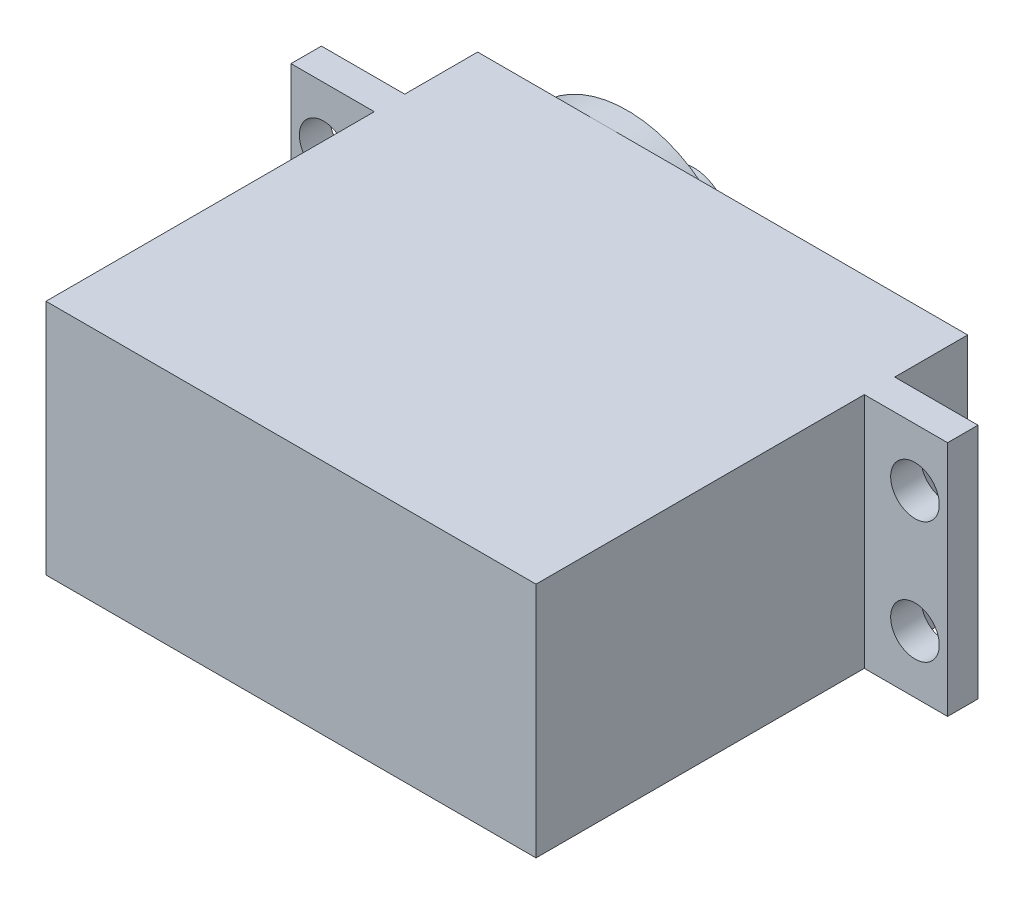
from build123d import *

# Parameters (mm, degrees)
SKETCH_1_W          = 40.3
SKETCH_1_H          = 19.5
EXTRUDE_1_DEPTH     = 27
SKETCH_2_W          = 6.85
SKETCH_2_H          = 19.5
SKETCH_2_R          = 2
SKETCH_2_W_2        = 20.15
EXTRUDE_2_DEPTH     = 2.5
SKETCH_3_W          = 40.3
SKETCH_3_H          = 19.5
EXTRUDE_3_DEPTH     = 6
EXTRUDE_4_DEPTH     = 2
SKETCH_5_R          = 6
EXTRUDE_5_DEPTH     = 1
SKETCH_6_R          = 2.9
EXTRUDE_6_DEPTH     = 4.5
SKETCH_7_R          = 1.5
CUT_EXTRUDE_1_DEPTH = 4.5


with BuildPart() as part:
    # 草图1 → 凸台-拉伸1 (new body)
    with BuildSketch(Plane.XY):
        Rectangle(SKETCH_1_W, SKETCH_1_H)
    extrude(amount=EXTRUDE_1_DEPTH)

    # 草图2 → 凸台-拉伸2 (add)
    with BuildSketch(Plane(origin=(0, 0, 0), x_dir=(-1, 0, 0), z_dir=(0, 0, -1))):
        with Locations((23.575, 0)):
            Rectangle(SKETCH_2_W, SKETCH_2_H)
        with Locations((24.315, -5)):
            Circle(SKETCH_2_R, mode=Mode.SUBTRACT)
        with Locations((24.315, 5)):
            Circle(SKETCH_2_R, mode=Mode.SUBTRACT)
        with Locations((10.075, 0)):
            Rectangle(SKETCH_2_W_2, SKETCH_2_H)
        with Locations((-23.575, 0)):
            Rectangle(SKETCH_2_W, SKETCH_2_H)
        with Locations((-24.315, -5)):
            Circle(SKETCH_2_R, mode=Mode.SUBTRACT)
        with Locations((-24.315, 5)):
            Circle(SKETCH_2_R, mode=Mode.SUBTRACT)
        with Locations((-10.075, 0)):
            Rectangle(SKETCH_2_W_2, SKETCH_2_H)
    extrude(amount=EXTRUDE_2_DEPTH)

    # 草图3 → 凸台-拉伸3 (add)
    with BuildSketch(Plane(origin=(0, 0, -2.5), x_dir=(-1, 0, 0), z_dir=(0, 0, -1))):
        Rectangle(SKETCH_3_W, SKETCH_3_H)
    extrude(amount=EXTRUDE_3_DEPTH)

    # 草图4 → 凸台-拉伸4 (add)
    with BuildSketch(Plane(origin=(0, 0, -8.5), x_dir=(-1, 0, 0), z_dir=(0, 0, -1))):
        with BuildLine():
            Line((3.774052971, 7.62531099), (-15.211090867, 7.62531099))
            Line((-15.211090867, 7.62531099), (-15.211090867, -7.62531099))
            Line((-15.211090867, -7.62531099), (3.774052971, -7.62531099))
            ThreePointArc((3.774052971, -7.62531099), (19.6, 0), (3.774052971, 7.62531099))
        make_face()
    extrude(amount=EXTRUDE_4_DEPTH)

    # 草图5 → 凸台-拉伸5 (add)
    with BuildSketch(Plane(origin=(0, 0, -10.5), x_dir=(-1, 0, 0), z_dir=(0, 0, -1))):
        with Locations((9.85, 0)):
            Circle(SKETCH_5_R)
    extrude(amount=EXTRUDE_5_DEPTH)

    # 草图6 → 凸台-拉伸6 (add)
    with BuildSketch(Plane(origin=(0, 0, -11.5), x_dir=(-1, 0, 0), z_dir=(0, 0, -1))):
        with Locations((9.85, 0)):
            Circle(SKETCH_6_R)
    extrude(amount=EXTRUDE_6_DEPTH)

    # 草图7 → 切除-拉伸1 (cut)
    with BuildSketch(Plane(origin=(0, 0, -16), x_dir=(-1, 0, 0), z_dir=(0, 0, -1))):
        with Locations((9.85, 0)):
            Circle(SKETCH_7_R)
    extrude(amount=-CUT_EXTRUDE_1_DEPTH, mode=Mode.SUBTRACT)


solid = part.part
